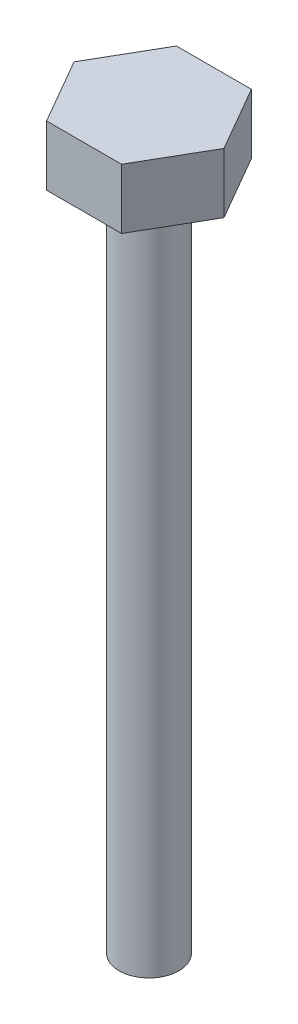
from build123d import *

# Parameters (mm, degrees)
SALIENTE_EXTRUIR1_DEPTH = 4
CROQUIS2_R              = 2
SALIENTE_EXTRUIR2_DEPTH = 45


with BuildPart() as part:
    # Croquis1 → Saliente-Extruir1 (new body)
    with BuildSketch(Plane(origin=(0, 0, 0), x_dir=(1, 0, 0), z_dir=(0, 1, 0))):
        Polygon((5, 0), (2.5, 4.330127019), (-2.5, 4.330127019), (-5, 0), (-2.5, -4.330127019), (2.5, -4.330127019), align=None)
    extrude(amount=SALIENTE_EXTRUIR1_DEPTH)

    # Croquis2 → Saliente-Extruir2 (add)
    with BuildSketch(Plane.XZ):
        Circle(CROQUIS2_R)
    extrude(amount=SALIENTE_EXTRUIR2_DEPTH)


solid = part.part
